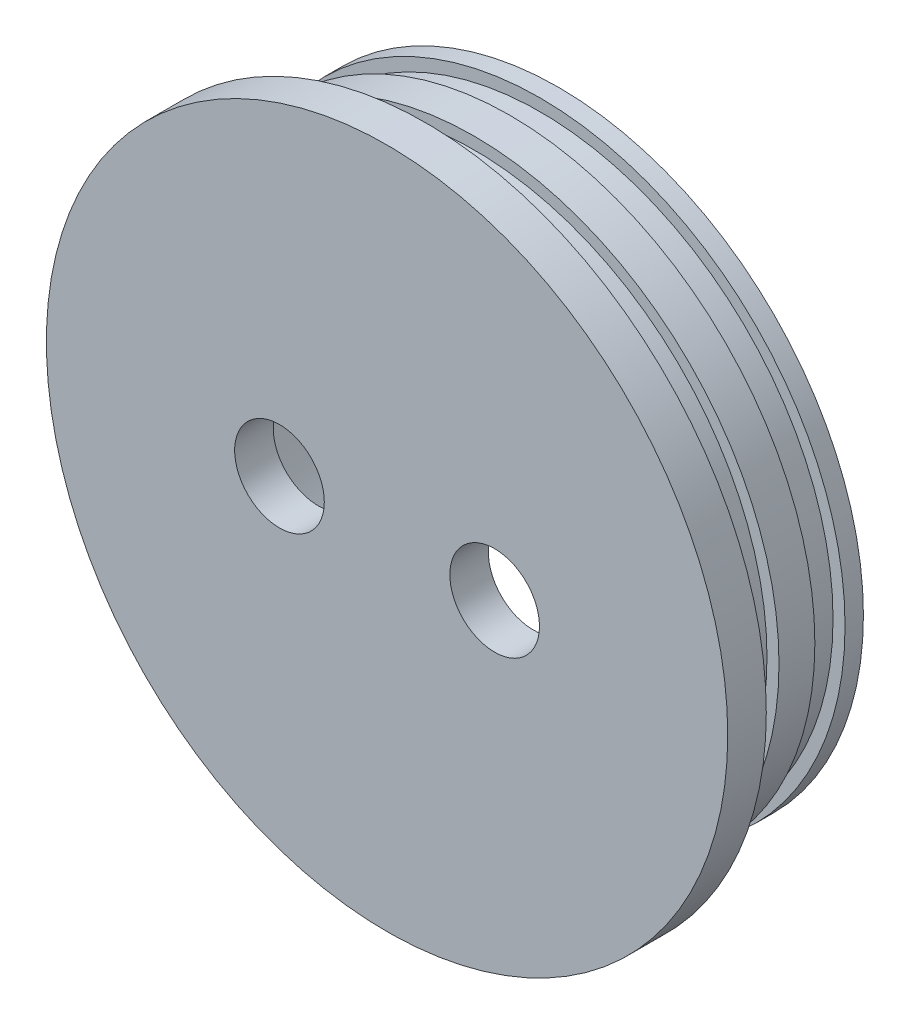
from build123d import *

# Parameters (mm, degrees)
SKETCH2_R          = 7.5
CUT_EXTRUDE2_DEPTH = 29.7


with BuildPart() as part:
    # Sketch1 → Revolve1 (revolve)
    with BuildSketch(Plane(origin=(0, 0, 0), x_dir=(0, 0, -1), z_dir=(1, 0, 0))):
        Polygon((-6.45, 6), (0, 6), (0, 0), (3.075, 0), (3.075, -2.009350098), (8.125, -2.009350098), (8.125, 0), (14.125, 0), (14.125, -2.009350098), (19.175, -2.009350098), (19.175, 0), (22.25, 0), (22.25, -7.6), (0, -7.6), (0, -51), (-6.45, -51), align=None)
    revolve(axis=Axis((0, -51, 6.45), (0, 0, -1)))

    # Sketch2 → Cut-Extrude2 (cut, through all)
    with BuildSketch(Plane.XY.offset(6.45)):
        with Locations((18, -51)):
            Circle(SKETCH2_R)
        with Locations((-18, -51)):
            Circle(SKETCH2_R)
    extrude(amount=-CUT_EXTRUDE2_DEPTH, mode=Mode.SUBTRACT)


solid = part.part
